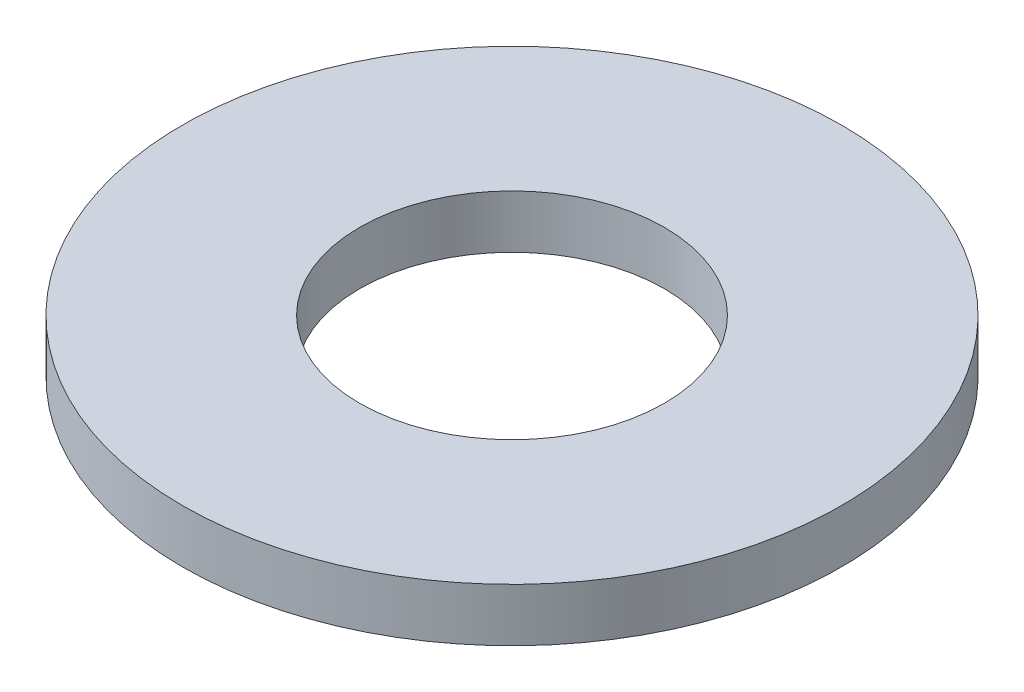
from build123d import *

# Parameters (mm, degrees)
SKETCH_1_R      = 9.3
SKETCH_1_R_2    = 4.3
EXTRUDE_1_DEPTH = 1.5


with BuildPart() as part:
    # 草图1 → 凸台-拉伸1 (new body)
    with BuildSketch(Plane(origin=(0, 0, 0), x_dir=(1, 0, 0), z_dir=(0, 1, 0))):
        Circle(SKETCH_1_R)
        Circle(SKETCH_1_R_2, mode=Mode.SUBTRACT)
    extrude(amount=EXTRUDE_1_DEPTH)


solid = part.part
